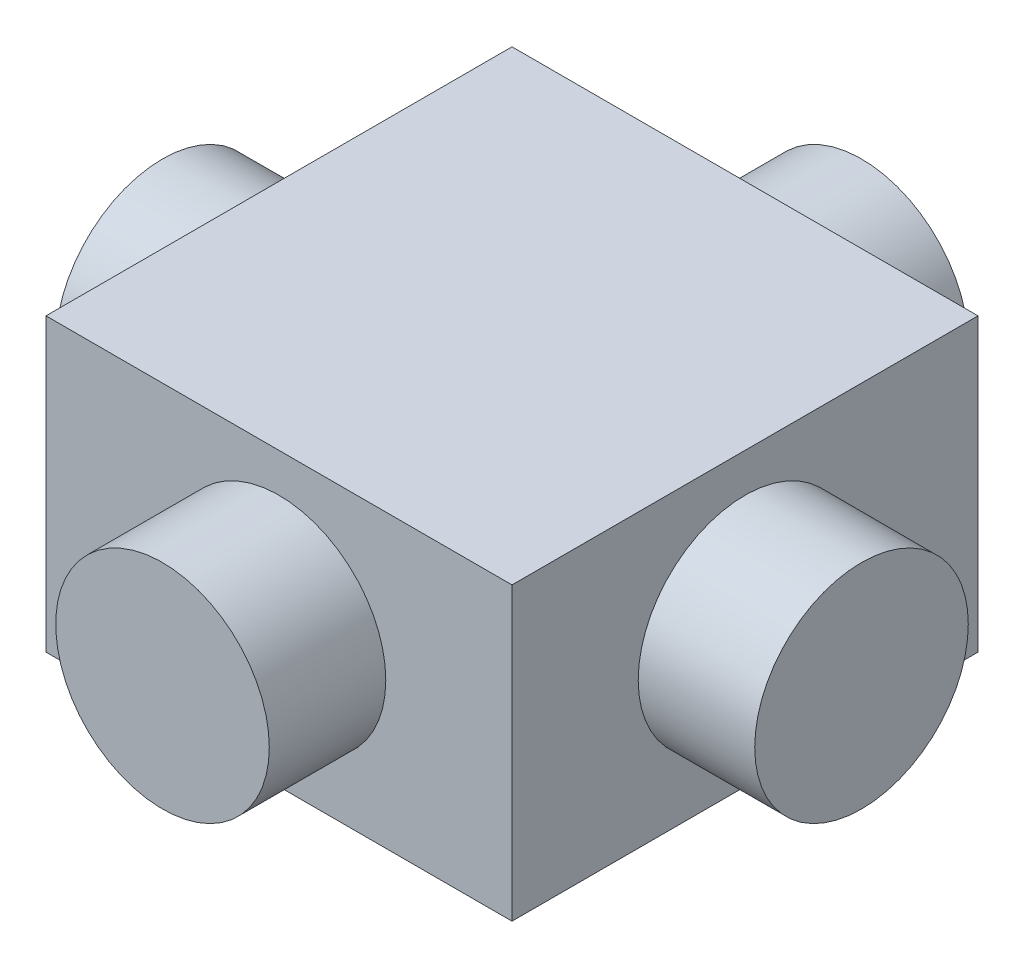
from build123d import *

# Parameters (mm, degrees)
SKETCH1_R           = 1.1
BOSS_EXTRUDE1_DEPTH = 3.6
CIRPATTERN1_COUNT   = 4
SKETCH3_W           = 4.8
SKETCH3_H           = 4.8
SKETCH3_W_2         = 2.2
SKETCH3_H_2         = 2.2
BOSS_EXTRUDE2_DEPTH = 1.5


with BuildPart() as part:
    # Sketch1 → Boss-Extrude1 (new, symmetric)
    with BuildSketch(Plane.XY):
        Circle(SKETCH1_R)
    boss_extrude1 = extrude(amount=BOSS_EXTRUDE1_DEPTH, both=True)

    # CirPattern1: Boss-Extrude1 ×4 about axis
    cirpattern1_axis = Axis((0, -1.485, 0), (0, 1, 0))
    for i in range(1, CIRPATTERN1_COUNT):
        add(boss_extrude1.rotate(cirpattern1_axis, i * 360 / CIRPATTERN1_COUNT))

    # Sketch3 → Boss-Extrude2 (add, symmetric)
    with BuildSketch(Plane(origin=(0, 0, 0), x_dir=(1, 0, 0), z_dir=(0, 1, 0))):
        Rectangle(SKETCH3_W, SKETCH3_H)
        Rectangle(SKETCH3_W_2, SKETCH3_H_2, mode=Mode.SUBTRACT)
        Rectangle(SKETCH3_W_2, SKETCH3_H_2)
    extrude(amount=BOSS_EXTRUDE2_DEPTH, both=True)


solid = part.part
